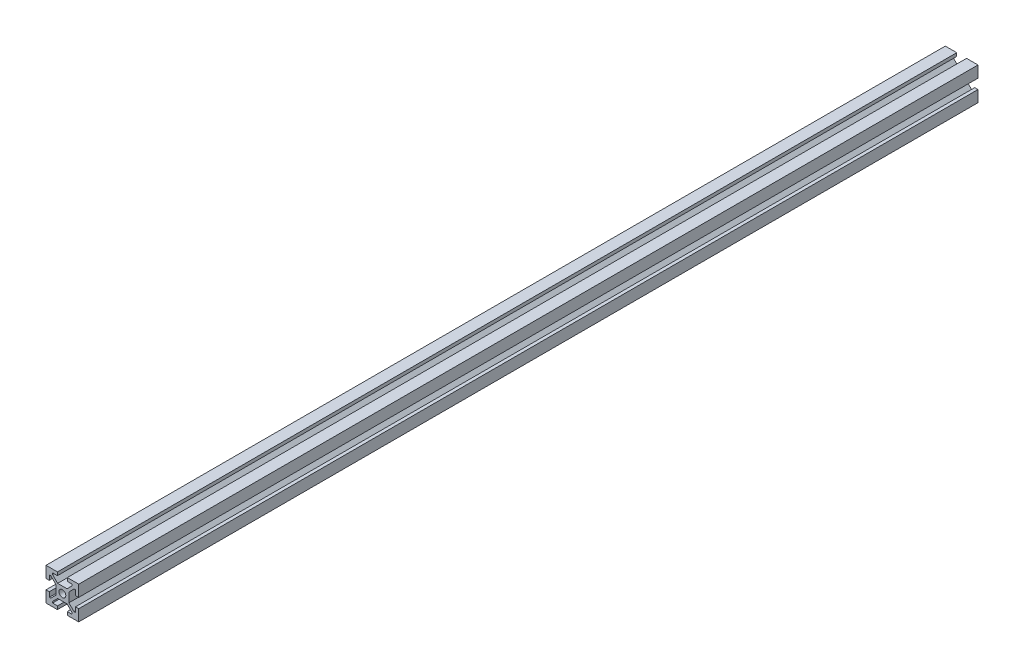
from build123d import *

# Parameters (mm, degrees)
CROQUIS1_R              = 2.1
SALIENTE_EXTRUIR1_DEPTH = 550


with BuildPart() as part:
    # Croquis1 → Saliente-Extruir1 (new body)
    with BuildSketch(Plane.XY.offset(420)):
        Polygon((-10, 10), (-10, 3), (-8, 3), (-8, 6), (-7.13137085, 6), (-4, 2.86862915), (-4, -2.86862915), (-7.13137085, -6), (-8, -6), (-8, -3), (-10, -3), (-10, -10), (-3, -10), (-3, -8), (-6, -8), (-6, -7.13137085), (-2.86862915, -4), (2.86862915, -4), (6, -7.13137085), (6, -8), (3, -8), (3, -10), (10, -10), (10, -3), (8, -3), (8, -6), (7.13137085, -6), (4, -2.86862915), (4, 2.86862915), (7.13137085, 6), (8, 6), (8, 3), (10, 3), (10, 10), (3, 10), (3, 8), (6, 8), (6, 7.13137085), (2.86862915, 4), (-2.86862915, 4), (-6, 7.13137085), (-6, 8), (-3, 8), (-3, 10), align=None)
        Circle(CROQUIS1_R, mode=Mode.SUBTRACT)
    extrude(amount=-SALIENTE_EXTRUIR1_DEPTH)


solid = part.part
